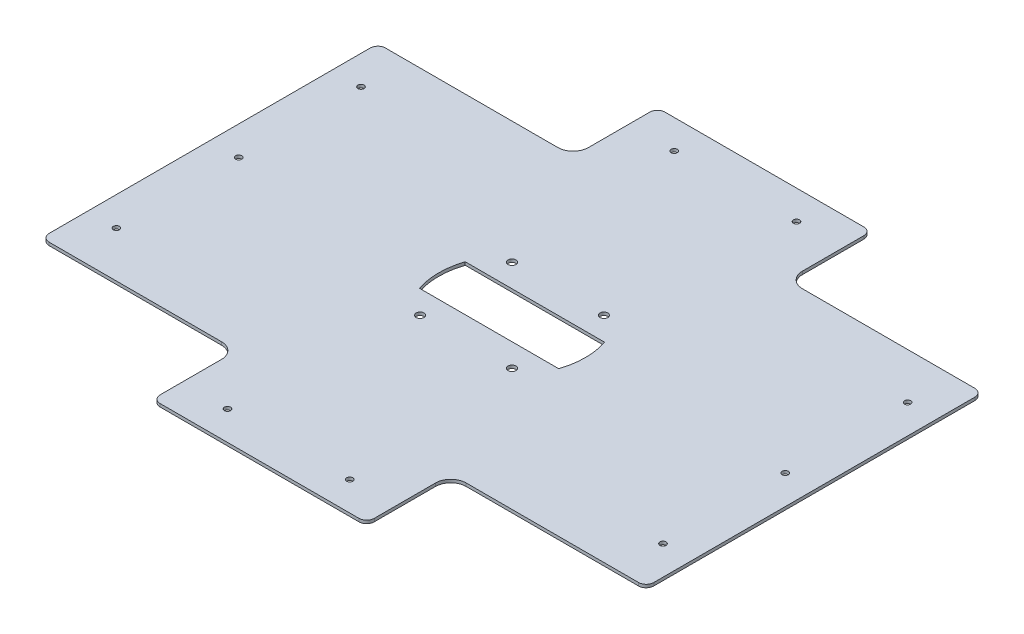
from build123d import *

# Parameters (mm, degrees)
SKETCH_1_R               = 2
EXTRUDE_1_DEPTH          = 2
CUT_EXTRUDE_2_DEPTH      = 3
PATTERN_CIRCULAR_1_COUNT = 4


with BuildPart() as part:
    # Эскиз1 → Бобышка-Вытянуть1 (new body)
    with BuildSketch(Plane(origin=(0, 0, 0), x_dir=(1, 0, 0), z_dir=(0, 1, 0))):
        with BuildLine():
            Line((-65, -165.104291208), (65, -165.104291208))
            ThreePointArc((65, -165.104291208), (68.535533906, -163.639825114), (70, -160.104291208))
            Line((70, -160.104291208), (70, -120))
            ThreePointArc((70, -120), (72.928932188, -112.928932188), (80, -110))
            Line((80, -110), (192.768667216, -110))
            ThreePointArc((192.768667216, -110), (196.304201122, -108.535533906), (197.768667216, -105))
            Line((197.768667216, -105), (197.768667216, 105))
            ThreePointArc((197.768667216, 105), (196.304201122, 108.535533906), (192.768667216, 110))
            Line((192.768667216, 110), (80, 110))
            ThreePointArc((80, 110), (72.928932188, 112.928932188), (70, 120))
            Line((70, 120), (70, 160.104291208))
            ThreePointArc((70, 160.104291208), (68.535533906, 163.639825114), (65, 165.104291208))
            Line((65, 165.104291208), (-65, 165.104291208))
            ThreePointArc((-65, 165.104291208), (-68.535533906, 163.639825114), (-70, 160.104291208))
            Line((-70, 160.104291208), (-70, 120))
            ThreePointArc((-70, 120), (-72.928932188, 112.928932188), (-80, 110))
            Line((-80, 110), (-192.768667216, 110))
            ThreePointArc((-192.768667216, 110), (-196.304201122, 108.535533906), (-197.768667216, 105))
            Line((-197.768667216, 105), (-197.768667216, -105))
            ThreePointArc((-197.768667216, -105), (-196.304201122, -108.535533906), (-192.768667216, -110))
            Line((-192.768667216, -110), (-80, -110))
            ThreePointArc((-80, -110), (-72.928932188, -112.928932188), (-70, -120))
            Line((-70, -120), (-70, -160.104291208))
            ThreePointArc((-70, -160.104291208), (-68.535533906, -163.639825114), (-65, -165.104291208))
        make_face()
        with Locations((178.768667216, 0)):
            Circle(SKETCH_1_R, mode=Mode.SUBTRACT)
        with Locations((178.768667216, 80)):
            Circle(SKETCH_1_R, mode=Mode.SUBTRACT)
        with Locations((178.768667216, -80)):
            Circle(SKETCH_1_R, mode=Mode.SUBTRACT)
        with Locations((-178.768667216, -80)):
            Circle(SKETCH_1_R, mode=Mode.SUBTRACT)
        with Locations((-178.768667216, 0)):
            Circle(SKETCH_1_R, mode=Mode.SUBTRACT)
        with Locations((-178.768667216, 80)):
            Circle(SKETCH_1_R, mode=Mode.SUBTRACT)
        with Locations((40, 146.104291208)):
            Circle(SKETCH_1_R, mode=Mode.SUBTRACT)
        with Locations((-40, 146.104291208)):
            Circle(SKETCH_1_R, mode=Mode.SUBTRACT)
        with Locations((-40, -146.104291208)):
            Circle(SKETCH_1_R, mode=Mode.SUBTRACT)
        with Locations((40, -146.104291208)):
            Circle(SKETCH_1_R, mode=Mode.SUBTRACT)
    extrude(amount=EXTRUDE_1_DEPTH)

    # Эскиз5 → Вырез-Вытянуть2 (cut, through all)
    with BuildSketch(Plane.XZ):
        with BuildLine():
            Line((45.596052461, -15), (-45.596052461, -15))
            ThreePointArc((-45.596052461, -15), (-48, 0), (-45.596052461, 15))
            Line((-45.596052461, 15), (45.596052461, 15))
            ThreePointArc((45.596052461, 15), (48, 0), (45.596052461, -15))
        make_face()
    extrude(amount=-CUT_EXTRUDE_2_DEPTH, mode=Mode.SUBTRACT)

    # Эскиз7 → Сверло под метчик  спиральное M51 (revolve, cut)
    with BuildSketch(Plane(origin=(30.0520382, 2, -30.0520382), x_dir=(0, 0, 1), z_dir=(1, 0, 0))):
        Polygon((0, 0), (0, 9.562237609), (2.6, 8), (2.6, 0), align=None)
    hole_wizard_m51 = revolve(axis=Axis((30.0520382, 8.35, -30.0520382), (0, -1, 0)), mode=Mode.SUBTRACT)

    # Круговой массив1: Сверло под метчик  спиральное M51 ×4 about axis
    pattern_circular_1_axis = Axis((0, 0, 0), (0, 1, 0))
    for i in range(1, PATTERN_CIRCULAR_1_COUNT):
        add(hole_wizard_m51.rotate(pattern_circular_1_axis, i * 360 / PATTERN_CIRCULAR_1_COUNT), mode=Mode.SUBTRACT)


solid = part.part
